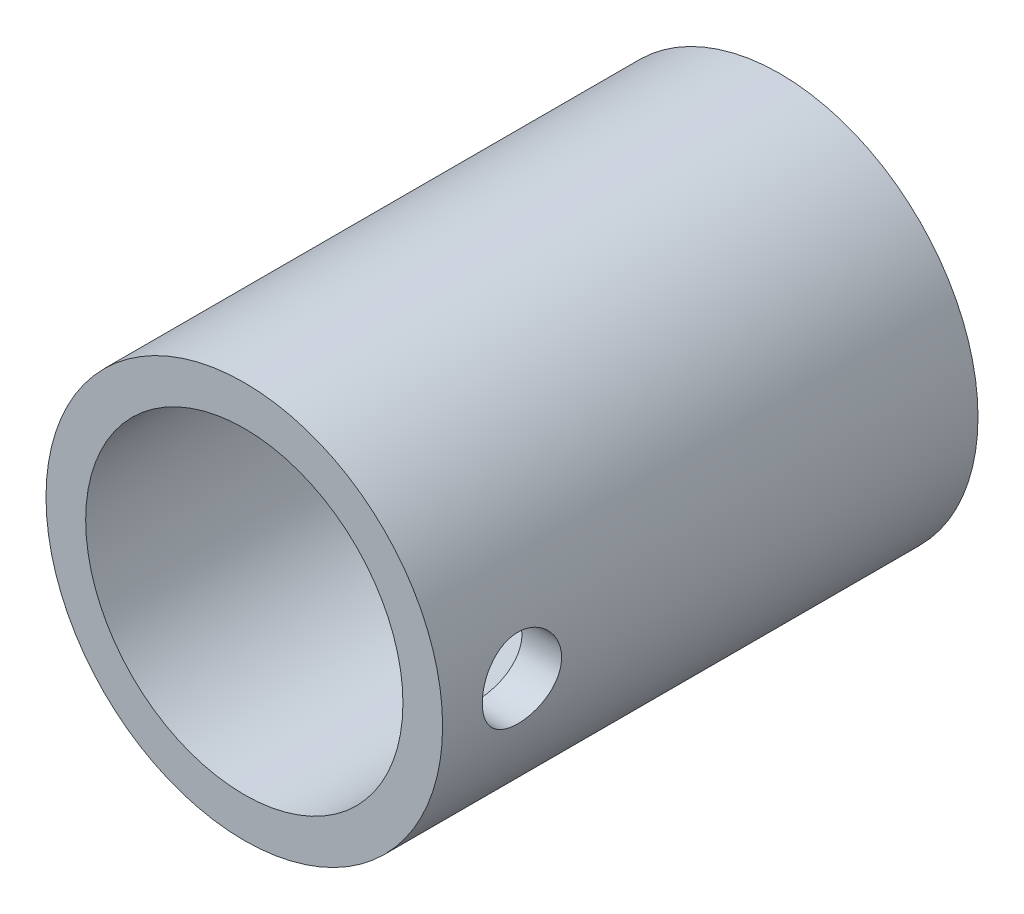
from build123d import *

# Parameters (mm, degrees)
SKETCH2_R           = 5
SKETCH2_R_2         = 4
BOSS_EXTRUDE1_DEPTH = 13.5
SKETCH3_R           = 1
CUT_EXTRUDE1_DEPTH  = 6.5


with BuildPart() as part:
    # Sketch2 → Boss-Extrude1 (new body)
    with BuildSketch(Plane.XY):
        Circle(SKETCH2_R)
        Circle(SKETCH2_R_2, mode=Mode.SUBTRACT)
    extrude(amount=BOSS_EXTRUDE1_DEPTH)

    # Sketch3 → Cut-Extrude1 (cut)
    with BuildSketch(Plane(origin=(0, 0, 0), x_dir=(0, 0, -1), z_dir=(1, 0, 0))):
        with Locations((-11.5, 0)):
            Circle(SKETCH3_R)
    extrude(amount=CUT_EXTRUDE1_DEPTH, mode=Mode.SUBTRACT)


solid = part.part
